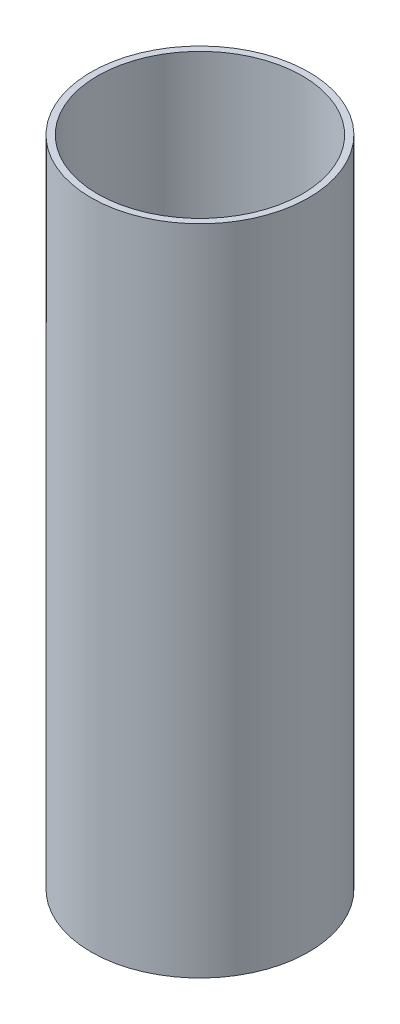
from build123d import *

# Parameters (mm, degrees)
SKETCH1_R   = 6.35
SKETCH1_R_2 = 5.969


with BuildPart() as part:
    # Sweep1: sweep along a path in Sketch2
    with BuildLine(Plane(origin=(0, 0, 0), x_dir=(0, 0, -1), z_dir=(1, 0, 0))) as sweep1_path:
        Line((0, 0), (0, 38.1))
    # Sketch1 → Sweep1 (sweep)
    with BuildSketch(Plane(origin=(0, 0, 0), x_dir=(1, 0, 0), z_dir=(0, 1, 0))):
        Circle(SKETCH1_R)
        Circle(SKETCH1_R_2, mode=Mode.SUBTRACT)
    sweep(path=sweep1_path.line)


solid = part.part
